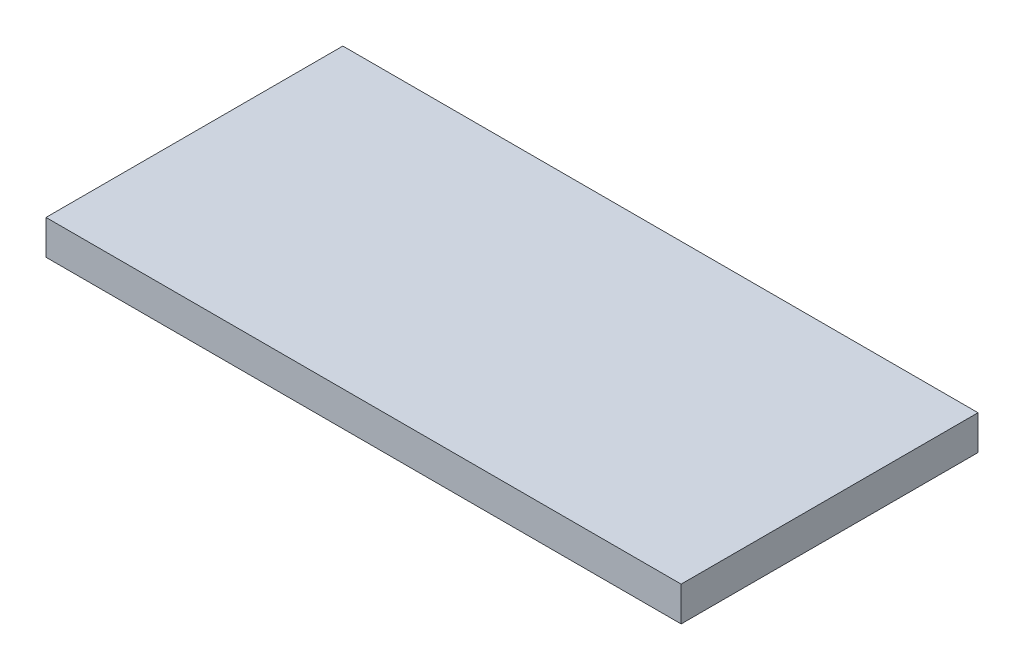
from build123d import *

# Parameters (mm, degrees)
SKETCH1_W                  = 184
SKETCH1_H                  = 86
BASE_DEPTH                 = 10
SKETCH2_R                  = 5.8
LOAD_CELL_BUTTON_CUT_DEPTH = 5.2


with BuildPart() as part:
    # Sketch1 → base (new body)
    with BuildSketch(Plane(origin=(0, 0, 0), x_dir=(1, 0, 0), z_dir=(0, 1, 0))):
        Rectangle(SKETCH1_W, SKETCH1_H)
    extrude(amount=BASE_DEPTH)

    # Sketch2 → load cell button cut (cut)
    with BuildSketch(Plane.XZ):
        Circle(SKETCH2_R)
    extrude(amount=-LOAD_CELL_BUTTON_CUT_DEPTH, mode=Mode.SUBTRACT)


solid = part.part
